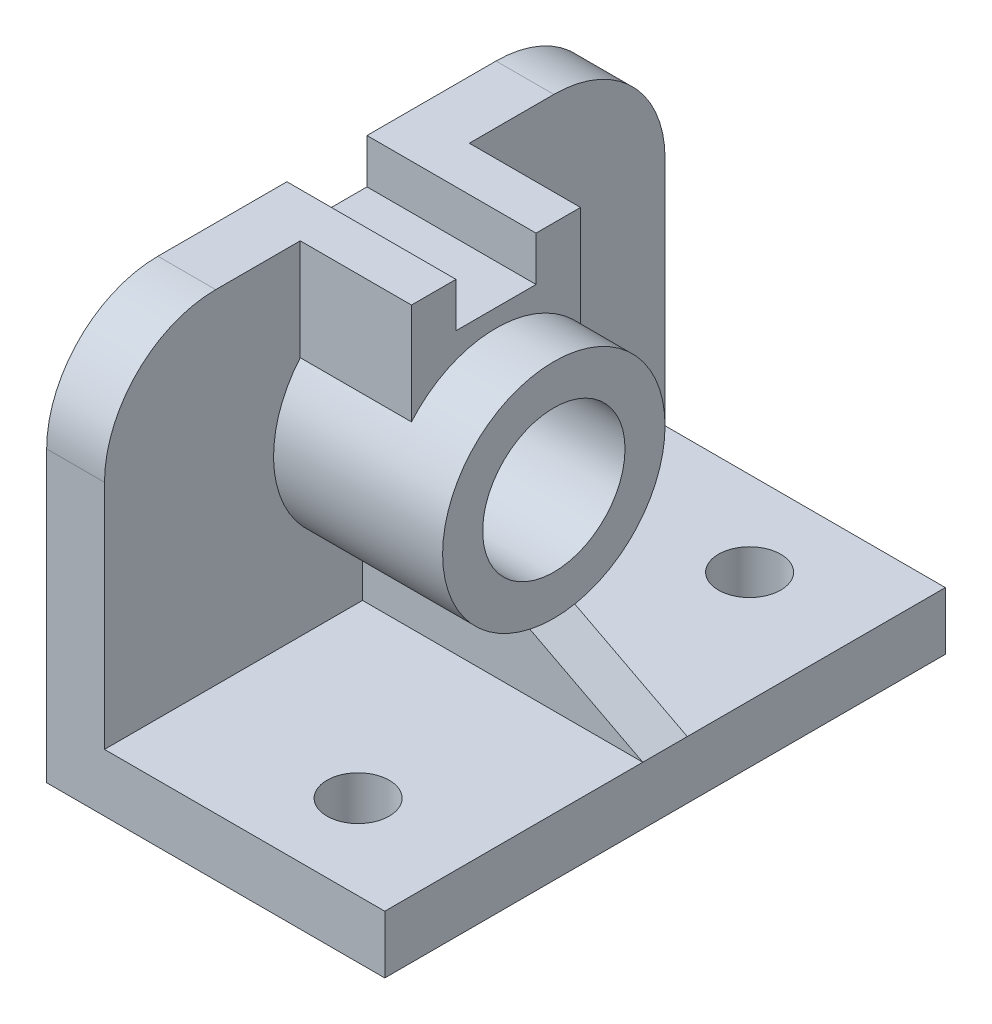
from build123d import *

# Parameters (mm, degrees)
SKETCH1_W           = 76
SKETCH1_H           = 126
BOSS_EXTRUDE1_DEPTH = 13
SKETCH2_W           = 13
SKETCH2_H           = 126
BOSS_EXTRUDE2_DEPTH = 77
FILLET1_R           = 25
SKETCH3_W           = 18
SKETCH3_H           = 10
CUT_EXTRUDE1_DEPTH  = 127.641225515
BOSS_EXTRUDE3_DEPTH = 25
SKETCH3_4_R         = 16
BOSS_EXTRUDE4_DEPTH = 38
RIB1_REACH          = 118.245
SKETCH4_WALL_W      = 262.668865642
SKETCH4_WALL_H      = 10
SKETCH5_R           = 7
CUT_EXTRUDE2_DEPTH  = 107.498826285
SKETCH3_5_R         = 16
CUT_EXTRUDE3_DEPTH  = 127.641225515


with BuildPart() as part:
    # Sketch1 → Boss-Extrude1 (new body)
    with BuildSketch(Plane(origin=(0, 0, 0), x_dir=(1, 0, 0), z_dir=(0, 1, 0))):
        Rectangle(SKETCH1_W, SKETCH1_H)
    extrude(amount=BOSS_EXTRUDE1_DEPTH)

    # Sketch2 → Boss-Extrude2 (add)
    with BuildSketch(Plane(origin=(0, 13, 0), x_dir=(1, 0, 0), z_dir=(0, 1, 0))):
        with Locations((-31.5, 0)):
            Rectangle(SKETCH2_W, SKETCH2_H)
    extrude(amount=BOSS_EXTRUDE2_DEPTH)

    # Fillet1
    fillet1_edges = [part.edges().sort_by_distance(p)[0] for p in [
        (-31.5, 90, -63),
        (-31.5, 90, 63),
    ]]
    fillet(fillet1_edges, radius=FILLET1_R)

    # Sketch3 → Cut-Extrude1 (cut, through all)
    with BuildSketch(Plane(origin=(-25, 0, 0), x_dir=(0, 0, -1), z_dir=(1, 0, 0))):
        with Locations((0, 85)):
            Rectangle(SKETCH3_W, SKETCH3_H)
    extrude(amount=-CUT_EXTRUDE1_DEPTH, mode=Mode.SUBTRACT)

    # Sketch3_3 → Boss-Extrude3 (add)
    with BuildSketch(Plane(origin=(-25, 0, 0), x_dir=(0, 0, -1), z_dir=(1, 0, 0))):
        with BuildLine():
            Line((-9, 80), (-9, 90))
            Line((-9, 90), (-19, 90))
            Line((-19, 90), (-19, 67.248076809))
            ThreePointArc((-19, 67.248076809), (0, 76), (19, 67.248076809))
            Line((19, 67.248076809), (19, 90))
            Line((19, 90), (9, 90))
            Line((9, 90), (9, 80))
            Line((9, 80), (-9, 80))
        make_face()
    extrude(amount=BOSS_EXTRUDE3_DEPTH)

    # Sketch3_4 → Boss-Extrude4 (add)
    with BuildSketch(Plane(origin=(-25, 0, 0), x_dir=(0, 0, -1), z_dir=(1, 0, 0))):
        with BuildLine():
            ThreePointArc((19, 67.248076809), (0, 76), (-19, 67.248076809))
            ThreePointArc((-19, 67.248076809), (-8.660254038, 27.547921201), (25, 51))
            ThreePointArc((25, 51), (23.452078799, 59.660254038), (19, 67.248076809))
        make_face()
        with Locations((0, 51)):
            Circle(SKETCH3_4_R, mode=Mode.SUBTRACT)
    extrude(amount=BOSS_EXTRUDE4_DEPTH)

    # Sketch4 wall → Rib1 (add, up to next)
    with BuildSketch(Plane(origin=(25.5, 19.5, 0), x_dir=(0.887216801235, -0.461352736642, 0), z_dir=(0.461352736642, 0.887216801235, 0)), mode=Mode.PRIVATE) as rib1_sk1:
        Rectangle(SKETCH4_WALL_W, SKETCH4_WALL_H)
    rib1_tool1 = extrude(rib1_sk1.sketch, amount=-RIB1_REACH, mode=Mode.PRIVATE) - part.part
    add(rib1_tool1.solids().sort_by_distance((25.5, 19.5, 0))[0])

    # Sketch5 → Cut-Extrude2 (cut, through all)
    with BuildSketch(Plane(origin=(0, 13, 0), x_dir=(1, 0, 0), z_dir=(0, 1, 0))):
        with Locations((13, -44)):
            Circle(SKETCH5_R)
        with Locations((13, 44)):
            Circle(SKETCH5_R)
    extrude(amount=-CUT_EXTRUDE2_DEPTH, mode=Mode.SUBTRACT)

    # Sketch3_5 → Cut-Extrude3 (cut, through all)
    with BuildSketch(Plane(origin=(-25, 0, 0), x_dir=(0, 0, -1), z_dir=(1, 0, 0))):
        with Locations((0, 51)):
            Circle(SKETCH3_5_R)
    extrude(amount=-CUT_EXTRUDE3_DEPTH, mode=Mode.SUBTRACT)


solid = part.part
